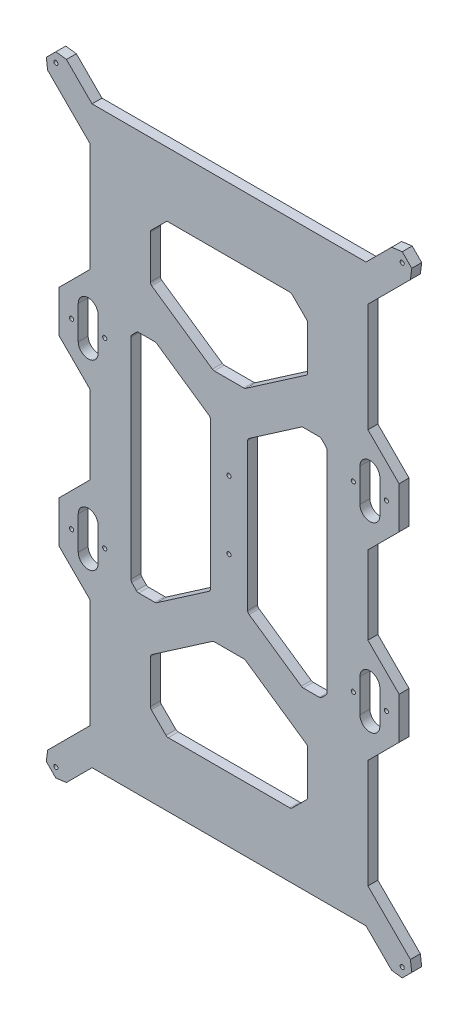
from build123d import *

# Parameters (mm, degrees)
SCHIZZO1_R                   = 1.25
ESTRUSIONE_ESTRUSIONE1_DEPTH = 6


with BuildPart() as part:
    # Schizzo1 → Estrusione-Estrusione1 (new body)
    with BuildSketch(Plane.XY):
        Polygon((-110.280237788, 184.011080088), (-104.511080088, 189.780237788), (-98.133615912, 188.947324411), (-82.653889721, 173.46759822), (82.653889721, 173.46759822), (98.133615912, 188.947324411), (104.511080088, 189.780237788), (110.280237788, 184.011080088), (109.447324411, 177.633615912), (83.818771539, 152.00506304), (83.818771539, 86.400644995), (102.629005707, 67.590410826), (102.629005707, 42.409589174), (83.818771539, 23.599355005), (83.818771539, -23.599355005), (102.629005707, -42.409589174), (102.629005707, -67.590410826), (83.818771539, -86.400644995), (83.818771539, -152.00506304), (109.447324411, -177.633615912), (110.280237788, -184.011080088), (104.511080088, -189.780237788), (98.133615912, -188.947324411), (82.653889721, -173.46759822), (-82.653889721, -173.46759822), (-98.133615912, -188.947324411), (-104.511080088, -189.780237788), (-110.280237788, -184.011080088), (-109.447324411, -177.633615912), (-83.818771539, -152.00506304), (-83.818771539, -86.400644995), (-102.629005707, -67.590410826), (-102.629005707, -42.409589174), (-83.818771539, -23.599355005), (-83.818771539, 23.599355005), (-102.629005707, 42.409589174), (-102.629005707, 67.590410826), (-83.818771539, 86.400644995), (-83.818771539, 152.00506304), (-109.447324411, 177.633615912), align=None)
        with Locations((-95, 55)):
            Circle(SCHIZZO1_R, mode=Mode.SUBTRACT)
        with Locations((-75, 55)):
            Circle(SCHIZZO1_R, mode=Mode.SUBTRACT)
        with Locations((-104.5, 184)):
            Circle(SCHIZZO1_R, mode=Mode.SUBTRACT)
        with Locations((0, 20.5)):
            Circle(SCHIZZO1_R, mode=Mode.SUBTRACT)
        with Locations((104.5, 184)):
            Circle(SCHIZZO1_R, mode=Mode.SUBTRACT)
        with Locations((75, 55)):
            Circle(SCHIZZO1_R, mode=Mode.SUBTRACT)
        with Locations((95, 55)):
            Circle(SCHIZZO1_R, mode=Mode.SUBTRACT)
        with Locations((95, -55)):
            Circle(SCHIZZO1_R, mode=Mode.SUBTRACT)
        with Locations((75, -55)):
            Circle(SCHIZZO1_R, mode=Mode.SUBTRACT)
        with Locations((104.5, -184)):
            Circle(SCHIZZO1_R, mode=Mode.SUBTRACT)
        with Locations((0, -20.5)):
            Circle(SCHIZZO1_R, mode=Mode.SUBTRACT)
        with Locations((-104.5, -184)):
            Circle(SCHIZZO1_R, mode=Mode.SUBTRACT)
        with Locations((-75, -55)):
            Circle(SCHIZZO1_R, mode=Mode.SUBTRACT)
        with Locations((-95, -55)):
            Circle(SCHIZZO1_R, mode=Mode.SUBTRACT)
        with BuildLine():
            Line((-59.232107436, 63.271672811), (-59.232107436, -63.271672811))
            ThreePointArc((-59.232107436, -63.271672811), (-59.085980675, -64.022108692), (-58.668953425, -64.662885808))
            Line((-58.668953425, -64.662885808), (-55.942526616, -67.478741779))
            ThreePointArc((-55.942526616, -67.478741779), (-55.285928666, -67.929053421), (-54.505680627, -68.087528781))
            Line((-54.505680627, -68.087528781), (-44.774099334, -68.087528781))
            ThreePointArc((-44.774099334, -68.087528781), (-44.179960459, -67.997240539), (-43.639465339, -67.734527779))
            Line((-43.639465339, -67.734527779), (-12.106917048, -46.011441546))
            ThreePointArc((-12.106917048, -46.011441546), (-11.471061282, -45.294693055), (-11.241551043, -44.364442549))
            Line((-11.241551043, -44.364442549), (-11.241551043, 44.364442549))
            ThreePointArc((-11.241551043, 44.364442549), (-11.471061282, 45.294693055), (-12.106917048, 46.011441546))
            Line((-12.106917048, 46.011441546), (-43.639465339, 67.734527779))
            ThreePointArc((-43.639465339, 67.734527779), (-44.179960459, 67.997240539), (-44.774099334, 68.087528781))
            Line((-44.774099334, 68.087528781), (-54.505680627, 68.087528781))
            ThreePointArc((-54.505680627, 68.087528781), (-55.285928666, 67.929053421), (-55.942526616, 67.478741779))
            Line((-55.942526616, 67.478741779), (-58.668953425, 64.662885808))
            ThreePointArc((-58.668953425, 64.662885808), (-59.085980675, 64.022108692), (-59.232107436, 63.271672811))
        make_face(mode=Mode.SUBTRACT)
        with BuildLine():
            Line((79, 45), (79, 65))
            ThreePointArc((79, 65), (85, 71), (91, 65))
            Line((91, 65), (91, 45))
            ThreePointArc((91, 45), (85, 39), (79, 45))
        make_face(mode=Mode.SUBTRACT)
        with BuildLine():
            Line((-47.48302182, 123.938863738), (-47.48302182, 97.979582184))
            ThreePointArc((-47.48302182, 97.979582184), (-47.253511581, 97.049331677), (-46.617655815, 96.332583186))
            Line((-46.617655815, 96.332583186), (-10.046187512, 71.138134825))
            ThreePointArc((-10.046187512, 71.138134825), (-9.505692391, 70.875422065), (-8.911553517, 70.785133823))
            Line((-8.911553517, 70.785133823), (8.911553517, 70.785133823))
            ThreePointArc((8.911553517, 70.785133823), (9.505692391, 70.875422065), (10.046187512, 71.138134825))
            Line((10.046187512, 71.138134825), (46.617655815, 96.332583186))
            ThreePointArc((46.617655815, 96.332583186), (47.253511581, 97.049331677), (47.48302182, 97.979582184))
            Line((47.48302182, 97.979582184), (47.48302182, 123.938863738))
            ThreePointArc((47.48302182, 123.938863738), (47.330780885, 124.704230603), (46.897235382, 125.353077301))
            Line((46.897235382, 125.353077301), (38.068808258, 134.181504425))
            ThreePointArc((38.068808258, 134.181504425), (37.41996156, 134.615049928), (36.654594695, 134.767290863))
            Line((36.654594695, 134.767290863), (-36.654594695, 134.767290863))
            ThreePointArc((-36.654594695, 134.767290863), (-37.41996156, 134.615049928), (-38.068808258, 134.181504425))
            Line((-38.068808258, 134.181504425), (-46.897235382, 125.353077301))
            ThreePointArc((-46.897235382, 125.353077301), (-47.330780885, 124.704230603), (-47.48302182, 123.938863738))
        make_face(mode=Mode.SUBTRACT)
        with BuildLine():
            Line((-79, 45), (-79, 65))
            ThreePointArc((-79, 65), (-85, 71), (-91, 65))
            Line((-91, 65), (-91, 45))
            ThreePointArc((-91, 45), (-85, 39), (-79, 45))
        make_face(mode=Mode.SUBTRACT)
        with BuildLine():
            Line((91, -45), (91, -65))
            ThreePointArc((91, -65), (85, -71), (79, -65))
            Line((79, -65), (79, -45))
            ThreePointArc((79, -45), (85, -39), (91, -45))
        make_face(mode=Mode.SUBTRACT)
        with BuildLine():
            Line((-79, -45), (-79, -65))
            ThreePointArc((-79, -65), (-85, -71), (-91, -65))
            Line((-91, -65), (-91, -45))
            ThreePointArc((-91, -45), (-85, -39), (-79, -45))
        make_face(mode=Mode.SUBTRACT)
        with BuildLine():
            Line((43.639465339, 67.734527779), (12.106917048, 46.011441546))
            ThreePointArc((12.106917048, 46.011441546), (11.471061282, 45.294693055), (11.241551043, 44.364442549))
            Line((11.241551043, 44.364442549), (11.241551043, -44.364442549))
            ThreePointArc((11.241551043, -44.364442549), (11.471061282, -45.294693055), (12.106917048, -46.011441546))
            Line((12.106917048, -46.011441546), (43.639465339, -67.734527779))
            ThreePointArc((43.639465339, -67.734527779), (44.179960459, -67.997240539), (44.774099334, -68.087528781))
            Line((44.774099334, -68.087528781), (54.505680627, -68.087528781))
            ThreePointArc((54.505680627, -68.087528781), (55.285928666, -67.929053421), (55.942526616, -67.478741779))
            Line((55.942526616, -67.478741779), (58.668953425, -64.662885808))
            ThreePointArc((58.668953425, -64.662885808), (59.085980675, -64.022108692), (59.232107436, -63.271672811))
            Line((59.232107436, -63.271672811), (59.232107436, 63.271672811))
            ThreePointArc((59.232107436, 63.271672811), (59.085980675, 64.022108692), (58.668953425, 64.662885808))
            Line((58.668953425, 64.662885808), (55.942526616, 67.478741779))
            ThreePointArc((55.942526616, 67.478741779), (55.285928666, 67.929053421), (54.505680627, 68.087528781))
            Line((54.505680627, 68.087528781), (44.774099334, 68.087528781))
            ThreePointArc((44.774099334, 68.087528781), (44.179960459, 67.997240539), (43.639465339, 67.734527779))
        make_face(mode=Mode.SUBTRACT)
        with BuildLine():
            Line((-36.654594695, -134.767290863), (36.654594695, -134.767290863))
            ThreePointArc((36.654594695, -134.767290863), (37.41996156, -134.615049928), (38.068808258, -134.181504425))
            Line((38.068808258, -134.181504425), (46.897235382, -125.353077301))
            ThreePointArc((46.897235382, -125.353077301), (47.330780885, -124.704230603), (47.48302182, -123.938863738))
            Line((47.48302182, -123.938863738), (47.48302182, -97.979582184))
            ThreePointArc((47.48302182, -97.979582184), (47.253511581, -97.049331677), (46.617655815, -96.332583186))
            Line((46.617655815, -96.332583186), (10.046187512, -71.138134825))
            ThreePointArc((10.046187512, -71.138134825), (9.505692391, -70.875422065), (8.911553517, -70.785133823))
            Line((8.911553517, -70.785133823), (-8.911553517, -70.785133823))
            ThreePointArc((-8.911553517, -70.785133823), (-9.505692391, -70.875422065), (-10.046187512, -71.138134825))
            Line((-10.046187512, -71.138134825), (-46.617655815, -96.332583186))
            ThreePointArc((-46.617655815, -96.332583186), (-47.253511581, -97.049331677), (-47.48302182, -97.979582184))
            Line((-47.48302182, -97.979582184), (-47.48302182, -123.938863738))
            ThreePointArc((-47.48302182, -123.938863738), (-47.330780885, -124.704230603), (-46.897235382, -125.353077301))
            Line((-46.897235382, -125.353077301), (-38.068808258, -134.181504425))
            ThreePointArc((-38.068808258, -134.181504425), (-37.41996156, -134.615049928), (-36.654594695, -134.767290863))
        make_face(mode=Mode.SUBTRACT)
    extrude(amount=-ESTRUSIONE_ESTRUSIONE1_DEPTH)


solid = part.part
